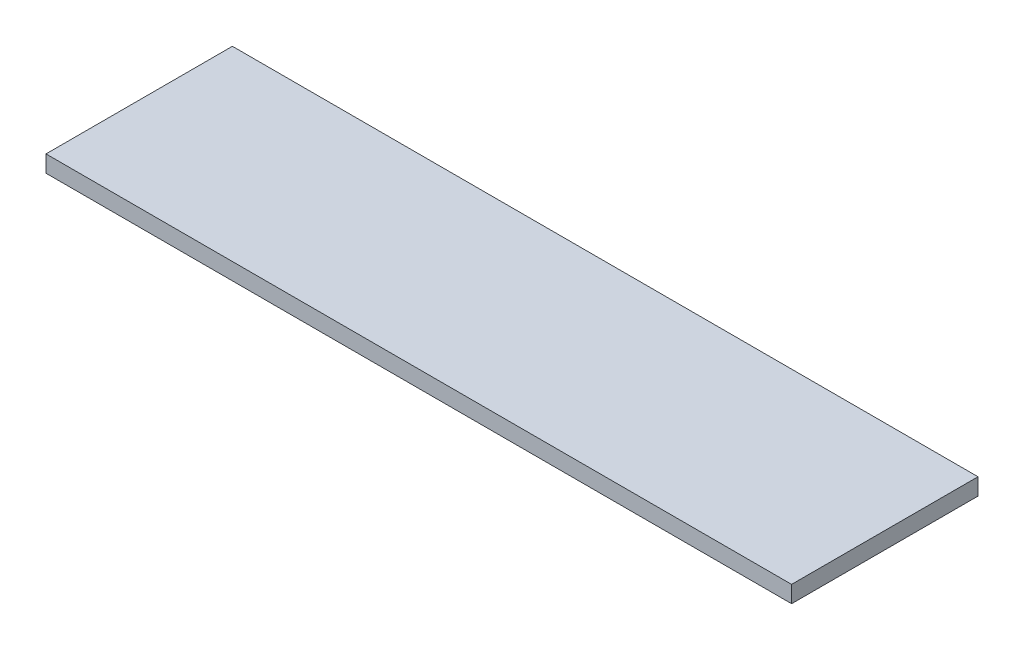
from build123d import *

# Parameters (mm, degrees)
SKETCH_1_W      = 80
SKETCH_1_H      = 20
EXTRUDE_1_DEPTH = 1.8


with BuildPart() as part:
    # 草图1 → 凸台-拉伸1 (new body)
    with BuildSketch(Plane(origin=(0, 0, 0), x_dir=(1, 0, 0), z_dir=(0, 1, 0))):
        with Locations((40, 10)):
            Rectangle(SKETCH_1_W, SKETCH_1_H)
    extrude(amount=EXTRUDE_1_DEPTH)


solid = part.part
